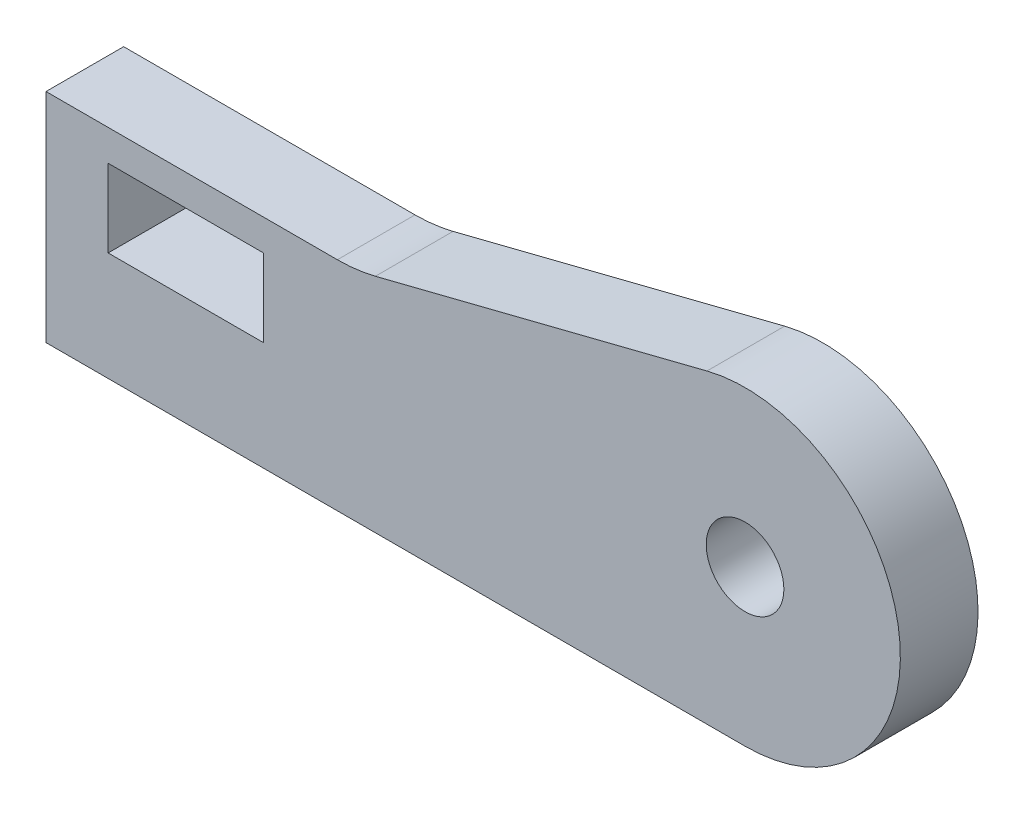
from build123d import *

# Parameters (mm, degrees)
SKETCH1_R           = 2.5
SKETCH1_W           = 10
SKETCH1_H           = 5
BOSS_EXTRUDE1_DEPTH = 5


with BuildPart() as part:
    # Sketch1 → Boss-Extrude1 (new body)
    with BuildSketch(Plane.XY):
        with BuildLine():
            Line((-24.313432836, 0), (20.686567164, 0))
            ThreePointArc((20.686567164, 0), (30.610164404, 11.23378192), (18.237856194, 19.695556435))
            Line((18.237856194, 19.695556435), (-3.108002795, 14.304443565))
            ThreePointArc((-3.108002795, 14.304443565), (-4.322931845, 14.07640276), (-5.556713765, 14))
            Line((-5.556713765, 14), (-24.313432836, 14))
            Line((-24.313432836, 14), (-24.313432836, 0))
        make_face()
        with Locations((20.686567164, 10)):
            Circle(SKETCH1_R, mode=Mode.SUBTRACT)
        with Locations((-15.313432836, 9.5)):
            Rectangle(SKETCH1_W, SKETCH1_H, mode=Mode.SUBTRACT)
    extrude(amount=BOSS_EXTRUDE1_DEPTH)


solid = part.part
